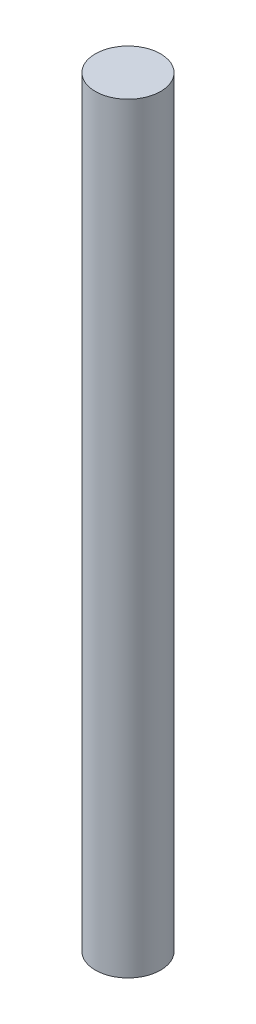
from build123d import *

# Parameters (mm, degrees)
SKETCH1_R           = 3
BOSS_EXTRUDE1_DEPTH = 70


with BuildPart() as part:
    # Sketch1 → Boss-Extrude1 (new body)
    with BuildSketch(Plane(origin=(0, 0, 0), x_dir=(1, 0, 0), z_dir=(0, 1, 0))):
        with Locations(Location((0, 0, 0), (0, 0, 270))):  # turned: the seam where the file's is
            Circle(SKETCH1_R)
    extrude(amount=BOSS_EXTRUDE1_DEPTH)


solid = part.part
